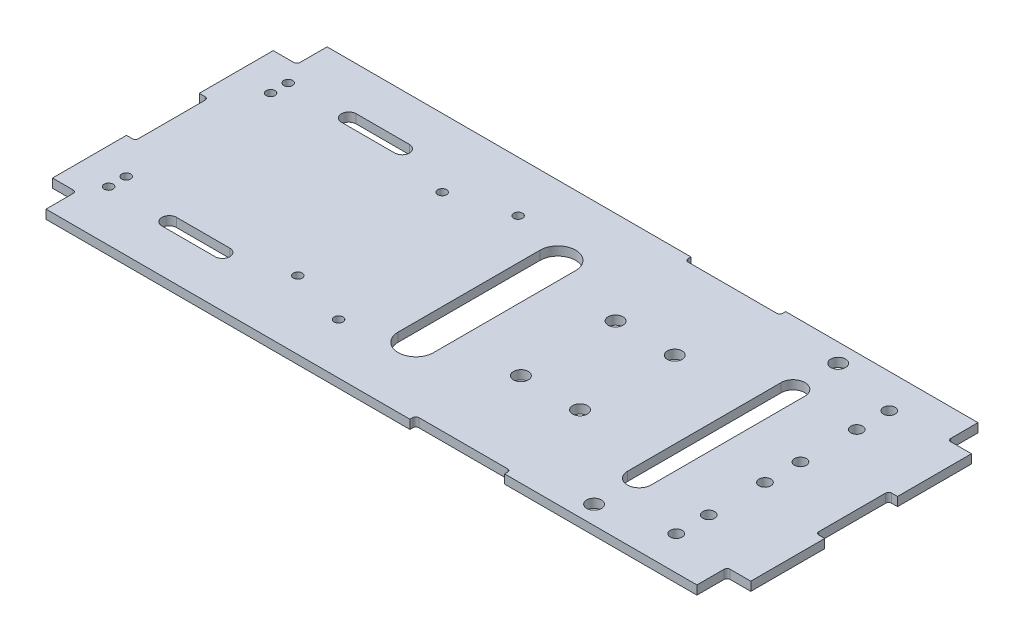
from build123d import *

# Parameters (mm, degrees)
SKETCH_4_W           = 236
SKETCH_4_H           = 95
EXTRUDE_3_DEPTH      = 3
SKETCH_5_W           = 3
SKETCH_5_H           = 12.3
CUT_EXTRUDE_1_DEPTH  = 4
SKETCH_6_W           = 8
SKETCH_6_H           = 10.2
CUT_EXTRUDE_2_DEPTH  = 4
FILLET_2_R           = 1
FILLET_5_R           = 1
SKETCH_7_W           = 3
SKETCH_7_H           = 12.3
CUT_EXTRUDE_3_DEPTH  = 4
FILLET_6_R           = 1
SKETCH_8_W           = 8
SKETCH_8_H           = 10.2
CUT_EXTRUDE_5_DEPTH  = 4
FILLET_9_R           = 1
SKETCH_10_W          = 3
SKETCH_10_H          = 12.3
CUT_EXTRUDE_6_DEPTH  = 4
SKETCH_11_W          = 3
SKETCH_11_H          = 12.3
CUT_EXTRUDE_7_DEPTH  = 4
SKETCH_12_W          = 8
SKETCH_12_H          = 10.2
CUT_EXTRUDE_8_DEPTH  = 4
SKETCH_13_W          = 8
SKETCH_13_H          = 10.2
CUT_EXTRUDE_10_DEPTH = 4
FILLET_13_R          = 1
FILLET_15_R          = 1
FILLET_18_R          = 1
FILLET_19_R          = 1
SKETCH_14_R          = 1.5
SKETCH_14_R_2        = 2
SKETCH_14_R_3        = 2.5
CUT_EXTRUDE_11_DEPTH = 4
SKETCH_15_W          = 32
SKETCH_15_H          = 4
CUT_EXTRUDE_12_DEPTH = 4
FILLET_20_R          = 1


with BuildPart() as part:
    # 草图4 → 凸台-拉伸3 (new body)
    with BuildSketch(Plane(origin=(0, 0, 0), x_dir=(1, 0, 0), z_dir=(0, 1, 0))):
        Rectangle(SKETCH_4_W, SKETCH_4_H)
    extrude(amount=EXTRUDE_3_DEPTH)

    # 草图5 → 切除-拉伸1 (cut, through all)
    with BuildSketch(Plane(origin=(0, 3, 0), x_dir=(1, 0, 0), z_dir=(0, 1, 0))):
        with Locations((-116.5, 6.15)):
            Rectangle(SKETCH_5_W, SKETCH_5_H)
    extrude(amount=-CUT_EXTRUDE_1_DEPTH, mode=Mode.SUBTRACT)

    # 草图6 → 切除-拉伸2 (cut, through all)
    with BuildSketch(Plane(origin=(0, 3, 0), x_dir=(1, 0, 0), z_dir=(0, 1, 0))):
        with Locations((-114, 42.4)):
            Rectangle(SKETCH_6_W, SKETCH_6_H)
    extrude(amount=-CUT_EXTRUDE_2_DEPTH, mode=Mode.SUBTRACT)

    # 圆角2
    fillet_2_edges = [part.edges().sort_by_distance(p)[0] for p in [
        (-110, 1.5, -37.3),
    ]]
    fillet(fillet_2_edges, radius=FILLET_2_R)

    # 圆角5
    fillet_5_edges = [part.edges().sort_by_distance(p)[0] for p in [
        (-115, 1.5, -12.3),
    ]]
    fillet(fillet_5_edges, radius=FILLET_5_R)

    # 草图7 → 切除-拉伸3 (cut, through all)
    with BuildSketch(Plane(origin=(0, 3, 0), x_dir=(1, 0, 0), z_dir=(0, 1, 0))):
        with Locations((-116.5, -6.15)):
            Rectangle(SKETCH_7_W, SKETCH_7_H)
    extrude(amount=-CUT_EXTRUDE_3_DEPTH, mode=Mode.SUBTRACT)

    # 圆角6
    fillet_6_edges = [part.edges().sort_by_distance(p)[0] for p in [
        (-115, 1.5, 12.3),
    ]]
    fillet(fillet_6_edges, radius=FILLET_6_R)

    # 草图8 → 切除-拉伸5 (cut, through all)
    with BuildSketch(Plane(origin=(0, 3, 0), x_dir=(1, 0, 0), z_dir=(0, 1, 0))):
        with Locations((-114, -42.4)):
            Rectangle(SKETCH_8_W, SKETCH_8_H)
    extrude(amount=-CUT_EXTRUDE_5_DEPTH, mode=Mode.SUBTRACT)

    # 圆角9
    fillet_9_edges = [part.edges().sort_by_distance(p)[0] for p in [
        (-110, 1.5, 37.3),
    ]]
    fillet(fillet_9_edges, radius=FILLET_9_R)

    # 草图10 → 切除-拉伸6 (cut, through all)
    with BuildSketch(Plane(origin=(0, 3, 0), x_dir=(1, 0, 0), z_dir=(0, 1, 0))):
        with Locations((116.5, 6.15)):
            Rectangle(SKETCH_10_W, SKETCH_10_H)
    extrude(amount=-CUT_EXTRUDE_6_DEPTH, mode=Mode.SUBTRACT)

    # 草图11 → 切除-拉伸7 (cut, through all)
    with BuildSketch(Plane(origin=(0, 3, 0), x_dir=(1, 0, 0), z_dir=(0, 1, 0))):
        with Locations((116.5, -6.15)):
            Rectangle(SKETCH_11_W, SKETCH_11_H)
    extrude(amount=-CUT_EXTRUDE_7_DEPTH, mode=Mode.SUBTRACT)

    # 草图12 → 切除-拉伸8 (cut, through all)
    with BuildSketch(Plane(origin=(0, 3, 0), x_dir=(1, 0, 0), z_dir=(0, 1, 0))):
        with Locations((114, 42.4)):
            Rectangle(SKETCH_12_W, SKETCH_12_H)
    extrude(amount=-CUT_EXTRUDE_8_DEPTH, mode=Mode.SUBTRACT)

    # 草图13 → 切除-拉伸10 (cut, through all)
    with BuildSketch(Plane(origin=(0, 3, 0), x_dir=(1, 0, 0), z_dir=(0, 1, 0))):
        with Locations((114, -42.4)):
            Rectangle(SKETCH_13_W, SKETCH_13_H)
    extrude(amount=-CUT_EXTRUDE_10_DEPTH, mode=Mode.SUBTRACT)

    # 圆角13
    fillet_13_edges = [part.edges().sort_by_distance(p)[0] for p in [
        (110, 1.5, -37.3),
    ]]
    fillet(fillet_13_edges, radius=FILLET_13_R)

    # 圆角15
    fillet_15_edges = [part.edges().sort_by_distance(p)[0] for p in [
        (110, 1.5, 37.3),
    ]]
    fillet(fillet_15_edges, radius=FILLET_15_R)

    # 圆角18
    fillet_18_edges = [part.edges().sort_by_distance(p)[0] for p in [
        (115, 1.5, 12.3),
    ]]
    fillet(fillet_18_edges, radius=FILLET_18_R)

    # 圆角19
    fillet_19_edges = [part.edges().sort_by_distance(p)[0] for p in [
        (115, 1.5, -12.3),
    ]]
    fillet(fillet_19_edges, radius=FILLET_19_R)

    # 草图14 → 切除-拉伸11 (cut, through all)
    with BuildSketch(Plane(origin=(0, 3, 0), x_dir=(1, 0, 0), z_dir=(0, 1, 0))):
        with Locations((-106, 30.35)):
            Circle(SKETCH_14_R)
        with Locations((-28.28, 30.35)):
            Circle(SKETCH_14_R)
        with Locations((-106, 24.4)):
            Circle(SKETCH_14_R)
        with Locations((-48, 24.4)):
            Circle(SKETCH_14_R)
        with Locations((91.5, 6)):
            Circle(SKETCH_14_R_2)
        with Locations((91.5, 25)):
            Circle(SKETCH_14_R_2)
        with Locations((91.5, 36)):
            Circle(SKETCH_14_R_2)
        with Locations((69, 41.25)):
            Circle(SKETCH_14_R_3)
        with Locations((39, 16)):
            Circle(SKETCH_14_R_3)
        with Locations((19, 16)):
            Circle(SKETCH_14_R_3)
        with Locations((91.5, -6)):
            Circle(SKETCH_14_R_2)
        with Locations((91.5, -25)):
            Circle(SKETCH_14_R_2)
        with Locations((91.5, -36)):
            Circle(SKETCH_14_R_2)
        with Locations((69, -41.25)):
            Circle(SKETCH_14_R_3)
        with Locations((39, -16)):
            Circle(SKETCH_14_R_3)
        with Locations((19, -16)):
            Circle(SKETCH_14_R_3)
        with Locations((-28.28, -30.35)):
            Circle(SKETCH_14_R)
        with Locations((-48, -24.4)):
            Circle(SKETCH_14_R)
        with Locations((-106, -24.4)):
            Circle(SKETCH_14_R)
        with Locations((-106, -30.35)):
            Circle(SKETCH_14_R)
        with BuildLine():
            Line((-2.5, 24), (-2.5, -24))
            ThreePointArc((-2.5, -24), (-8.5, -30), (-14.5, -24))
            Line((-14.5, -24), (-14.5, 24))
            ThreePointArc((-14.5, 24), (-8.5, 30), (-2.5, 24))
        make_face()
        with BuildLine():
            Line((73, 26), (73, -26))
            ThreePointArc((73, -26), (69, -30), (65, -26))
            Line((65, -26), (65, 26))
            ThreePointArc((65, 26), (69, 30), (73, 26))
        make_face()
        with BuildLine():
            Line((-85.5, 32.85), (-67.5, 32.85))
            ThreePointArc((-67.5, 32.85), (-65, 30.35), (-67.5, 27.85))
            Line((-67.5, 27.85), (-85.5, 27.85))
            ThreePointArc((-85.5, 27.85), (-88, 30.35), (-85.5, 32.85))
        make_face()
        with BuildLine():
            Line((-85.5, -32.85), (-67.5, -32.85))
            ThreePointArc((-67.5, -32.85), (-65, -30.35), (-67.5, -27.85))
            Line((-67.5, -27.85), (-85.5, -27.85))
            ThreePointArc((-85.5, -27.85), (-88, -30.35), (-85.5, -32.85))
        make_face()
    extrude(amount=-CUT_EXTRUDE_11_DEPTH, mode=Mode.SUBTRACT)

    # 草图15 → 切除-拉伸12 (cut, through all)
    with BuildSketch(Plane(origin=(0, 3, 0), x_dir=(1, 0, 0), z_dir=(0, 1, 0))):
        with Locations((29, 47.5)):
            Rectangle(SKETCH_15_W, SKETCH_15_H)
        with Locations((29, -47.5)):
            Rectangle(SKETCH_15_W, SKETCH_15_H)
    extrude(amount=-CUT_EXTRUDE_12_DEPTH, mode=Mode.SUBTRACT)

    # 圆角20
    fillet_20_edges = [part.edges().sort_by_distance(p)[0] for p in [
        (13, 1.5, -45.5),
        (45, 1.5, -45.5),
        (45, 1.5, 45.5),
        (13, 1.5, 45.5),
    ]]
    fillet(fillet_20_edges, radius=FILLET_20_R)


solid = part.part
